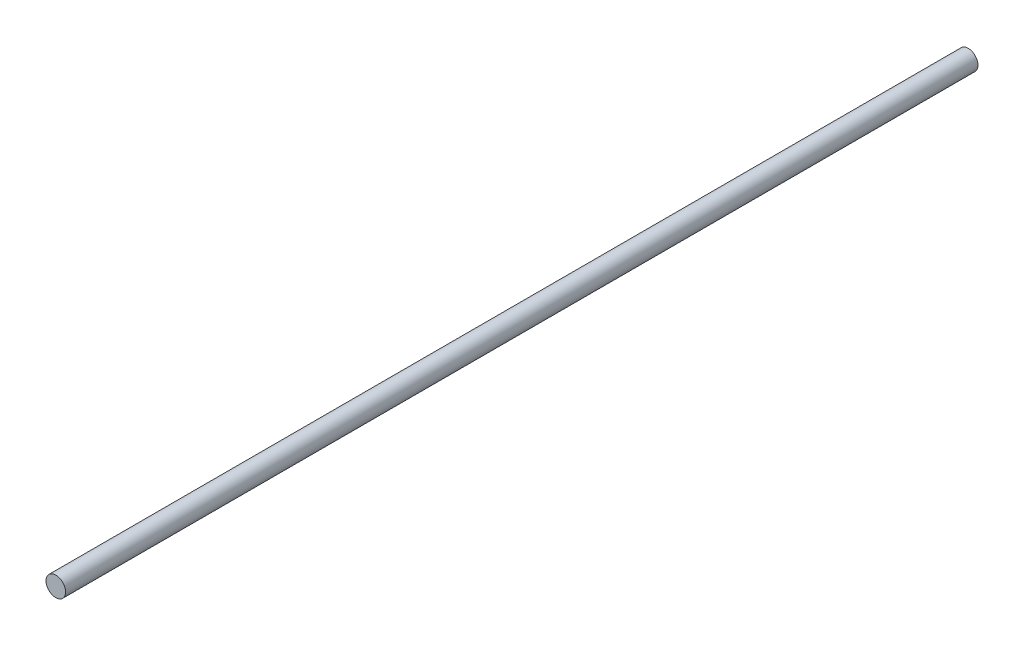
from build123d import *

# Parameters (mm, degrees)
ESBO_O1_R                = 4
RESSALTO_EXTRUS_O1_DEPTH = 373


with BuildPart() as part:
    # Esboço1 → Ressalto-extrusão1 (new body)
    with BuildSketch(Plane.XY):
        Circle(ESBO_O1_R)
    extrude(amount=RESSALTO_EXTRUS_O1_DEPTH)


solid = part.part
